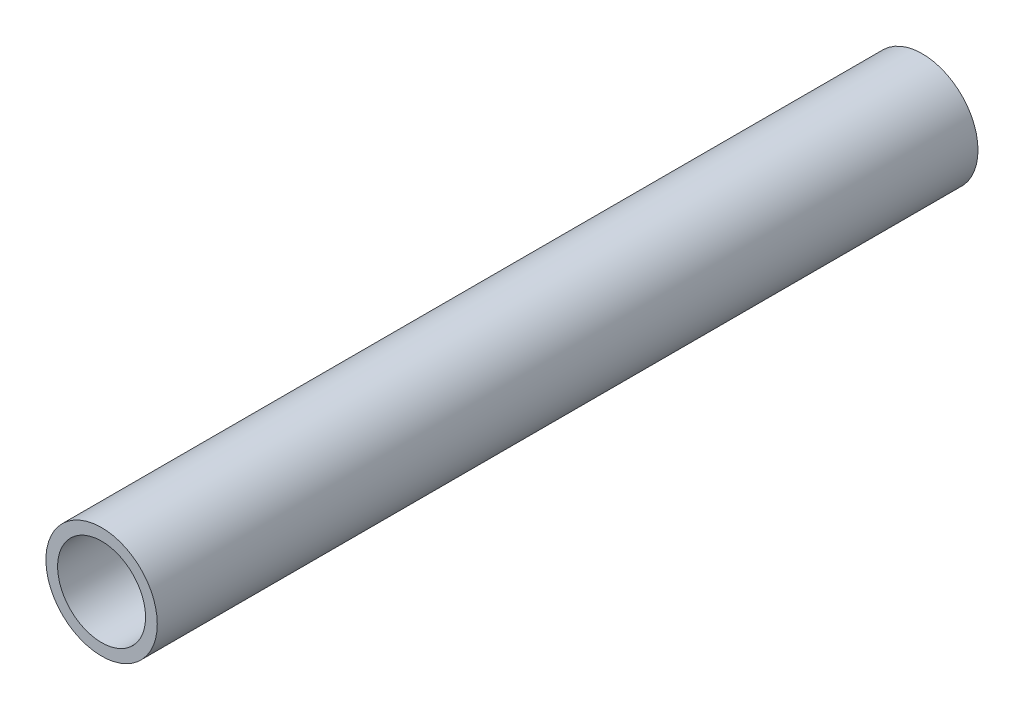
from build123d import *

# Parameters (mm, degrees)
SKETCH1_R           = 4.75
SKETCH1_R_2         = 3.75
BOSS_EXTRUDE2_DEPTH = 70


with BuildPart() as part:
    # Sketch1 → Boss-Extrude2 (new body)
    with BuildSketch(Plane.XY):
        Circle(SKETCH1_R)
        Circle(SKETCH1_R_2, mode=Mode.SUBTRACT)
    extrude(amount=BOSS_EXTRUDE2_DEPTH)


solid = part.part
